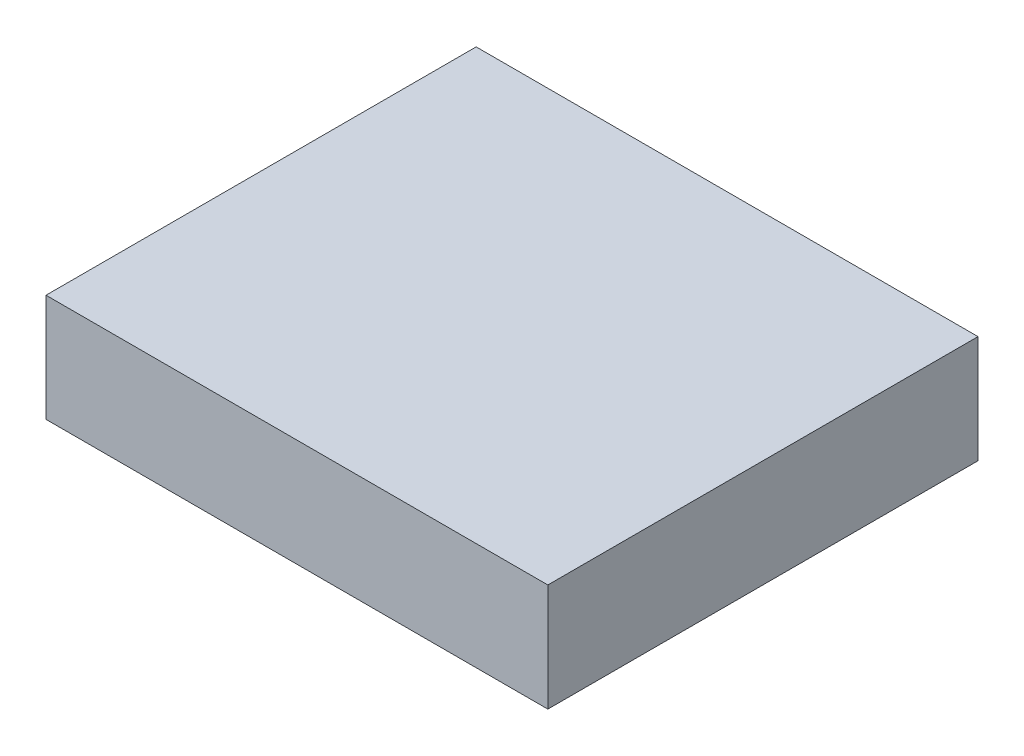
from build123d import *

# Parameters (mm, degrees)
SKETCH1_W           = 3.5
SKETCH1_H           = 3
BOSS_EXTRUDE1_DEPTH = 0.75


with BuildPart() as part:
    # Sketch1 → Boss-Extrude1 (new body)
    with BuildSketch(Plane(origin=(0, 0, 0), x_dir=(1, 0, 0), z_dir=(0, 1, 0))):
        with Locations((-0.091503268, -0.630718954)):
            Rectangle(SKETCH1_W, SKETCH1_H)
    extrude(amount=BOSS_EXTRUDE1_DEPTH)


solid = part.part
